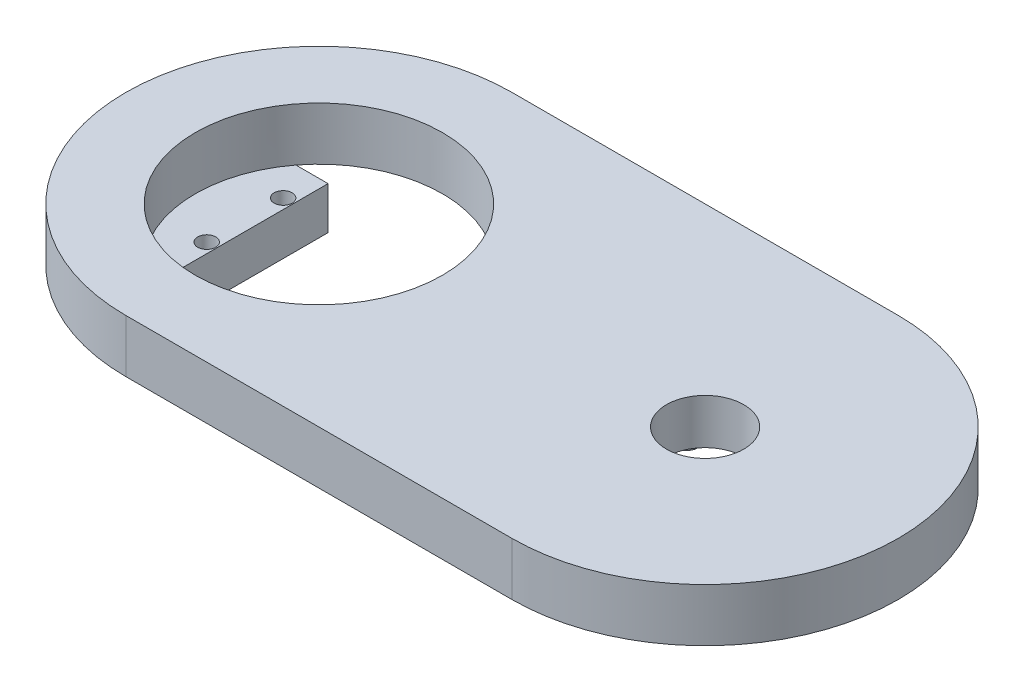
from build123d import *

# Parameters (mm, degrees)
BOSS_EXTRUDE1_DEPTH      = 6.86
SKETCH2_R                = 5
SKETCH2_R_2              = 16
CUT_EXTRUDE1_DEPTH       = 6.86
SKETCH3_W                = 11.5
SKETCH3_H                = 19
SKETCH3_W_2              = 7
BOSS_EXTRUDE2_DEPTH      = 5.5
SKETCH4_R                = 1.165
CUT_EXTRUDE2_DEPTH       = 12.5
SKETCH6_R                = 12
CUT_EXTRUDE3_DEPTH       = 1
SKETCH7_R                = 1.5
SKETCH7_R_2              = 1.493707415
BOSS_EXTRUDE5_DEPTH      = 1
BOSS_EXTRUDE5_DEPTH_BACK = 1


with BuildPart() as part:
    # Sketch1 → Boss-Extrude1 (new body)
    with BuildSketch(Plane(origin=(0, 0, 0), x_dir=(1, 0, 0), z_dir=(0, 1, 0))):
        with BuildLine():
            Line((-13.264052164, 25), (36.735947836, 25))
            ThreePointArc((36.735947836, 25), (61.735947836, 0), (36.735947836, -25))
            Line((36.735947836, -25), (-13.264052164, -25))
            ThreePointArc((-13.264052164, -25), (-38.264052164, 0), (-13.264052164, 25))
        make_face()
    extrude(amount=BOSS_EXTRUDE1_DEPTH)

    # Sketch2 → Cut-Extrude1 (cut)
    with BuildSketch(Plane(origin=(0, 6.86, 0), x_dir=(1, 0, 0), z_dir=(0, 1, 0))):
        with Locations((36.735947836, 0)):
            Circle(SKETCH2_R)
        with Locations((-13.264052164, 0)):
            Circle(SKETCH2_R_2)
    extrude(amount=-CUT_EXTRUDE1_DEPTH, mode=Mode.SUBTRACT)

    # Sketch3 → Boss-Extrude2 (add)
    with BuildSketch(Plane.XZ):
        with Locations((-27.554052164, -0.231081814)):
            Rectangle(SKETCH3_W, SKETCH3_H)
        with Locations((18.195874459, -0.141240273)):
            Rectangle(SKETCH3_W_2, SKETCH3_H)
    extrude(amount=BOSS_EXTRUDE2_DEPTH)

    # Sketch4 → Cut-Extrude2 (cut)
    with BuildSketch(Plane.XZ.offset(5.5)):
        with Locations((-23.104052164, 4.678918186)):
            Circle(SKETCH4_R)
        with Locations((-23.104052164, -5.211081814)):
            Circle(SKETCH4_R)
    extrude(amount=-CUT_EXTRUDE2_DEPTH, mode=Mode.SUBTRACT)

    # Sketch6 → Cut-Extrude3 (cut)
    with BuildSketch(Plane(origin=(0, 0, 0), x_dir=(1, 0, 0), z_dir=(0, 1, 0))):
        with Locations((36.735947836, 0)):
            Circle(SKETCH6_R)
    extrude(amount=CUT_EXTRUDE3_DEPTH, mode=Mode.SUBTRACT)

    # Sketch7 → Boss-Extrude5 (add, two sides)
    with BuildSketch(Plane(origin=(0, 0, 0), x_dir=(1, 0, 0), z_dir=(0, 1, 0))) as boss_extrude5_sk:
        with Locations((36.735947836, -9)):
            Circle(SKETCH7_R)
        with Locations((29.268034032, 5.059173887)):
            Circle(SKETCH7_R_2)
        with Locations((44.243842587, 4.965825904)):
            Circle(SKETCH7_R)
    extrude(amount=BOSS_EXTRUDE5_DEPTH)
    extrude(boss_extrude5_sk.sketch, amount=-BOSS_EXTRUDE5_DEPTH_BACK)


solid = part.part
